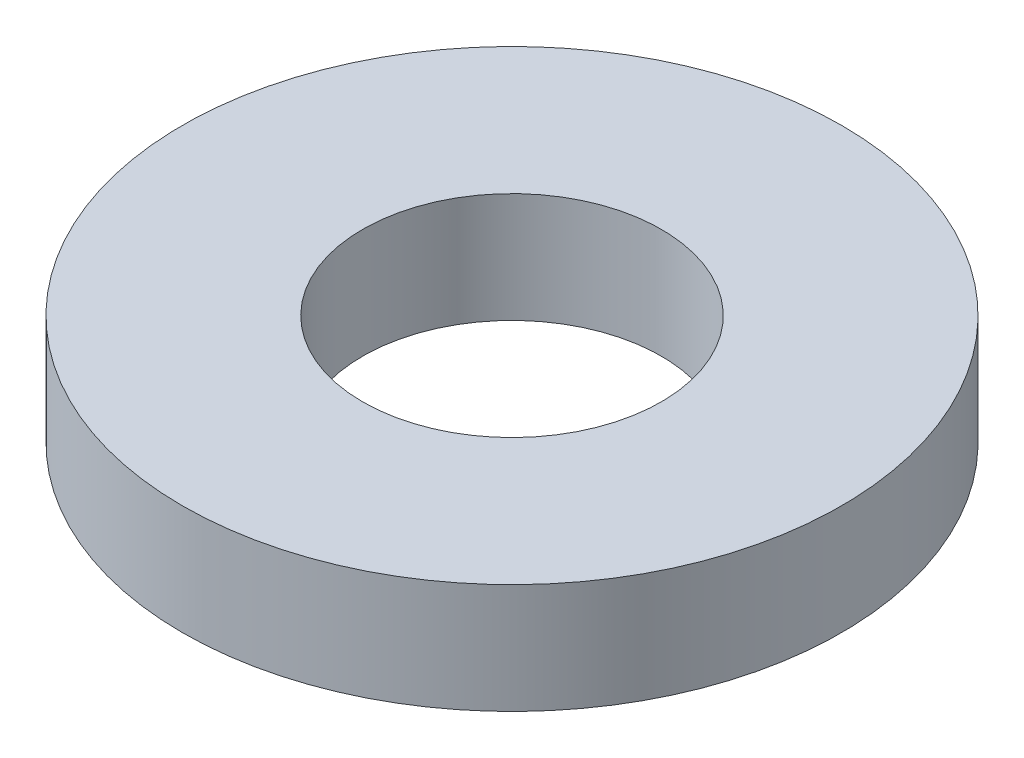
from build123d import *

# Parameters (mm, degrees)
SKETCH1_R           = 4.7625
SKETCH1_R_2         = 2.159
BOSS_EXTRUDE1_DEPTH = 1.5875


with BuildPart() as part:
    # Sketch1 → Boss-Extrude1 (new body)
    with BuildSketch(Plane(origin=(0, 0, 0), x_dir=(1, 0, 0), z_dir=(0, 1, 0))):
        Circle(SKETCH1_R)
        Circle(SKETCH1_R_2, mode=Mode.SUBTRACT)
    extrude(amount=BOSS_EXTRUDE1_DEPTH)


solid = part.part
